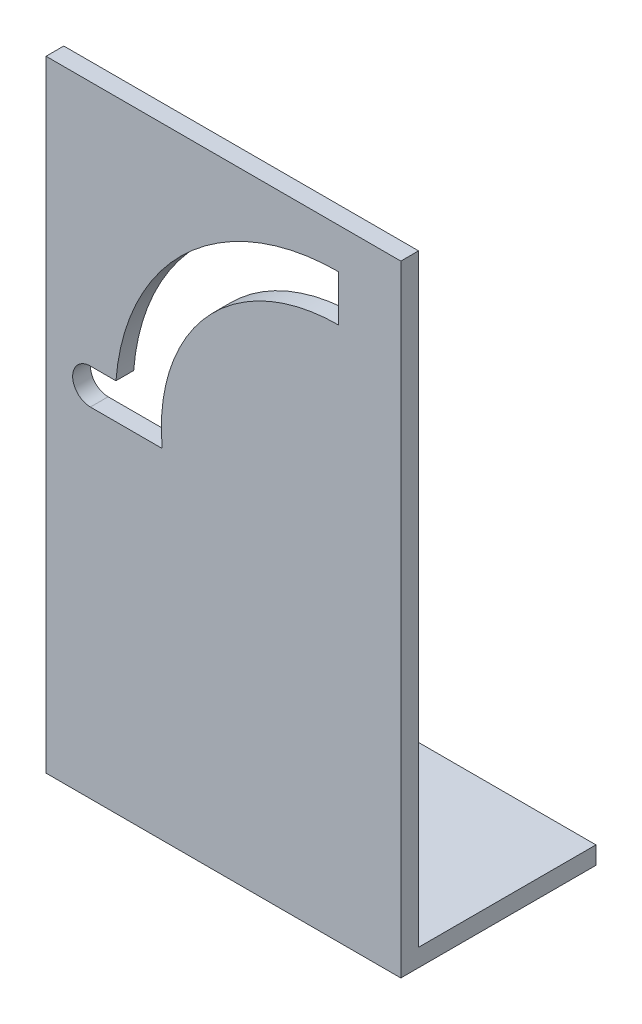
from build123d import *

# Parameters (mm, degrees)
SKETCH_1_W      = 40
SKETCH_1_H      = 70
EXTRUDE_1_DEPTH = 2
SKETCH_2_W      = 40
SKETCH_2_H      = 2
EXTRUDE_2_DEPTH = 22


with BuildPart() as part:
    # 草图1 → 凸台-拉伸1 (new body)
    with BuildSketch(Plane.XY):
        with Locations((-10.271445819, -4.719420773)):
            Rectangle(SKETCH_1_W, SKETCH_1_H)
        with BuildLine():
            Line((-25.271445819, -1.469420773), (-21.271445819, -1.469420773))
            Line((-21.271445819, -1.469420773), (-17.171194561, -1.469420773))
            ThreePointArc((-17.171194561, -1.469420773), (-12.103842793, 13.946987092), (2.728554181, 20.530579227))
            Line((2.728554181, 20.530579227), (2.728554181, 25.730579227))
            ThreePointArc((2.728554181, 25.730579227), (-14.368814038, 19.043277572), (-22.391955368, 2.530579227))
            Line((-22.391955368, 2.530579227), (-25.271445819, 2.530579227))
            ThreePointArc((-25.271445819, 2.530579227), (-27.271445819, 0.530579227), (-25.271445819, -1.469420773))
        make_face(mode=Mode.SUBTRACT)
    extrude(amount=EXTRUDE_1_DEPTH)

    # 草图2 → 凸台-拉伸2 (add)
    with BuildSketch(Plane.XY.offset(2)):
        with Locations((-10.271445819, -38.719420773)):
            Rectangle(SKETCH_2_W, SKETCH_2_H)
    extrude(amount=-EXTRUDE_2_DEPTH)


solid = part.part
